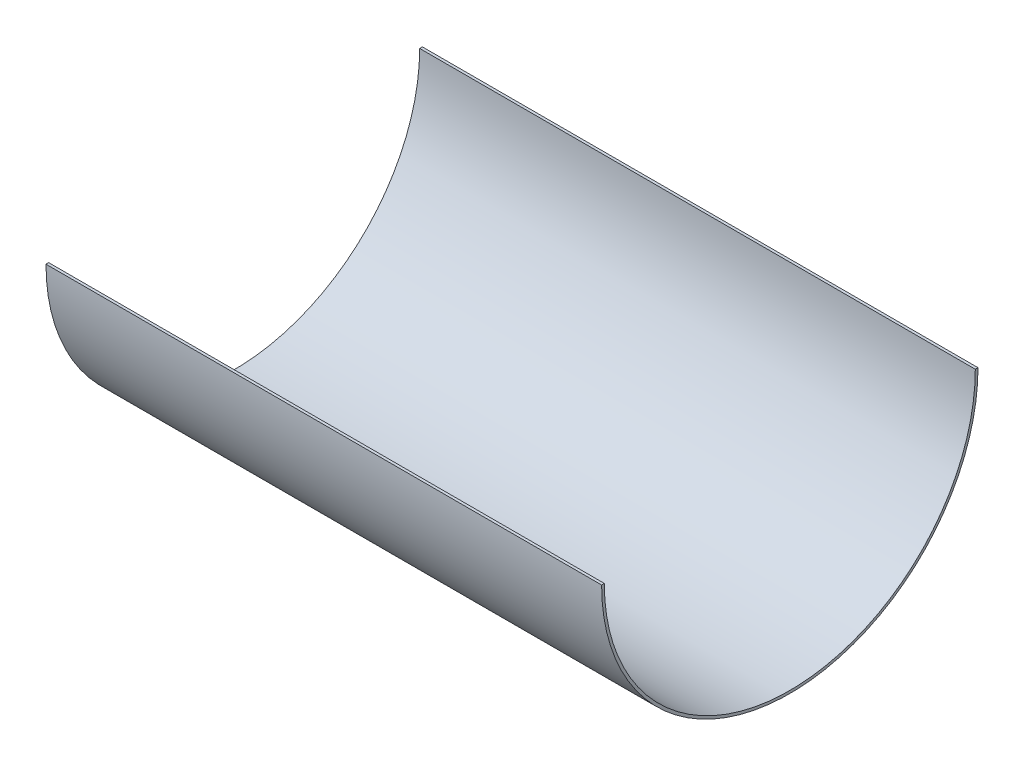
from build123d import *

# Parameters (mm, degrees)
SKETCH4_W          = 958.607886296
SKETCH4_H          = 357.948466727
CUT_EXTRUDE2_DEPTH = 620
SKETCH5_W          = 348.415387901
SKETCH5_H          = 679.160017281
SKETCH5_W_2        = 379.676333146
SKETCH5_H_2        = 859.178335114
CUT_EXTRUDE3_DEPTH = 500


with BuildPart() as part:
    # Sketch1 → Revolve1 (revolve)
    with BuildSketch(Plane(origin=(0, 0, 0), x_dir=(1, 0, 0), z_dir=(0, 1, 0)), mode=Mode.PRIVATE) as revolve1_sk:
        with BuildLine():
            Line((-38.416122965, -102.435963202), (581.583877035, -102.435963202))
            add(Edge.make_bspline(
                [(581.583877035, -102.435963202), (693.455539681, -103.300064727), (691.583877035, -210.80239754), (691.583877035, -232.435963192)],
                knots=[0, 0, 0, 0, 1, 1, 1, 1], degree=3))
            Line((691.583877035, -232.435963192), (688.583877035, -232.435963192))
            add(Edge.make_bspline(
                [(581.572240946, -105.435963202), (582.424150652, -105.442600659), (584.137918536, -105.468851395), (587.484086921, -105.571526796), (591.571096113, -105.792916991), (596.307608869, -106.20262694), (602.409126826, -106.934758126), (609.639419087, -108.18665603), (617.705857071, -110.190510236), (625.186745256, -112.659295822), (634.414245375, -116.523312816), (644.612073728, -122.339029978), (654.913796392, -130.630357057), (663.469285855, -139.982021209), (670.450391217, -150.141502012), (676.016737994, -160.847618745), (680.323342136, -171.829037867), (683.525745861, -182.806951112), (685.782094183, -193.498408861), (687.253383878, -203.618874424), (687.961369137, -211.339785332), (688.299442483, -216.947462036), (688.459593049, -220.834002423), (688.547117141, -224.365875375), (688.582824389, -227.512914091), (688.58674237, -229.777140481), (688.584795317, -231.383827189), (688.583877035, -232.075985649), (688.583877035, -232.435963192)],
                knots=[3.4973e-05, 3.4973e-05, 3.4973e-05, 3.4973e-05, 0.0078472, 0.015659426, 0.03128388, 0.046908334, 0.062532787, 0.093781694, 0.125030601, 0.156279508, 0.187528415, 0.25002623, 0.312524044, 0.375021858, 0.437519672, 0.500017486, 0.562515301, 0.625013115, 0.687510929, 0.750008743, 0.812506557, 0.843755465, 0.875004372, 0.906253279, 0.937502186, 0.968751093, 0.984375546, 1, 1, 1, 1], degree=3))
            Line((581.572240946, -105.435963202), (-38.416122951, -105.435969803))
            add(Edge.make_bspline(
                [(-145.416150087, -297.448719694), (-145.415786094, -297.363118797), (-145.414261278, -297.209117302), (-145.406482156, -296.763589127), (-145.387577621, -296.059017238), (-145.348080967, -294.963719442), (-145.270536885, -293.196191663), (-145.12221169, -290.430217628), (-144.846888777, -286.292241124), (-144.459106758, -281.402026013), (-143.771963774, -273.967299792), (-142.556325425, -263.124157442), (-140.406308296, -248.159348272), (-137.445210779, -231.767940973), (-133.55430361, -214.477141353), (-128.616651259, -196.81526366), (-122.518262583, -179.311948455), (-115.149922932, -162.497881736), (-106.409989847, -146.903194531), (-96.207058742, -133.05233616), (-86.417989624, -123.386032183), (-77.769632288, -117.014146282), (-70.859172034, -112.970513688), (-63.504748075, -109.716446776), (-56.985343251, -107.708604585), (-51.52041341, -106.554160283), (-47.294097057, -105.922162765), (-43.659473987, -105.597170774), (-40.689467236, -105.462466746), (-39.171234927, -105.437583269), (-38.416122951, -105.435969803)],
                knots=[2.115e-05, 2.115e-05, 2.115e-05, 2.115e-05, 0.007833485, 0.015645819, 0.031270489, 0.046895159, 0.062519828, 0.093769167, 0.125018506, 0.156267845, 0.187517184, 0.250015862, 0.312514541, 0.375013219, 0.437511897, 0.500010575, 0.562509253, 0.625007931, 0.687506609, 0.750005287, 0.812503966, 0.843753305, 0.875002644, 0.906251983, 0.937501322, 0.953125991, 0.968750661, 0.98437533, 0.992187665, 1, 1, 1, 1], degree=3))
            Line((-145.416150087, -297.448719694), (-148.416122965, -297.435963202))
            add(Edge.make_bspline(
                [(-38.416122965, -102.435963202), (-139.444928363, -102.64405425), (-148.369931417, -286.57299354), (-148.416122965, -297.435963202)],
                knots=[0, 0, 0, 0, 1, 1, 1, 1], degree=3))
        make_face()
    revolve(revolve1_sk.sketch.rotate(Axis((-396.592099756, 0, 312.435963202), (1, 0, 0)), 180), axis=Axis((-396.592099756, 0, 312.435963202), (1, 0, 0)))

    # Sketch4 → Cut-Extrude2 (cut)
    with BuildSketch(Plane(origin=(-38.416122965, 0, 0), x_dir=(0, 0, -1), z_dir=(1, 0, 0))):
        with Locations((-258.191988159, 178.974233364)):
            Rectangle(SKETCH4_W, SKETCH4_H)
    extrude(amount=CUT_EXTRUDE2_DEPTH, mode=Mode.SUBTRACT)

    # Sketch5 → Cut-Extrude3 (cut, symmetric)
    with BuildSketch(Plane(origin=(0, 0, 0), x_dir=(1, 0, 0), z_dir=(0, 1, 0))):
        with Locations((-212.623816916, -235.263662883)):
            Rectangle(SKETCH5_W, SKETCH5_H)
        with Locations((771.422043608, -306.861857476)):
            Rectangle(SKETCH5_W_2, SKETCH5_H_2)
    extrude(amount=CUT_EXTRUDE3_DEPTH, both=True, mode=Mode.SUBTRACT)


solid = part.part
